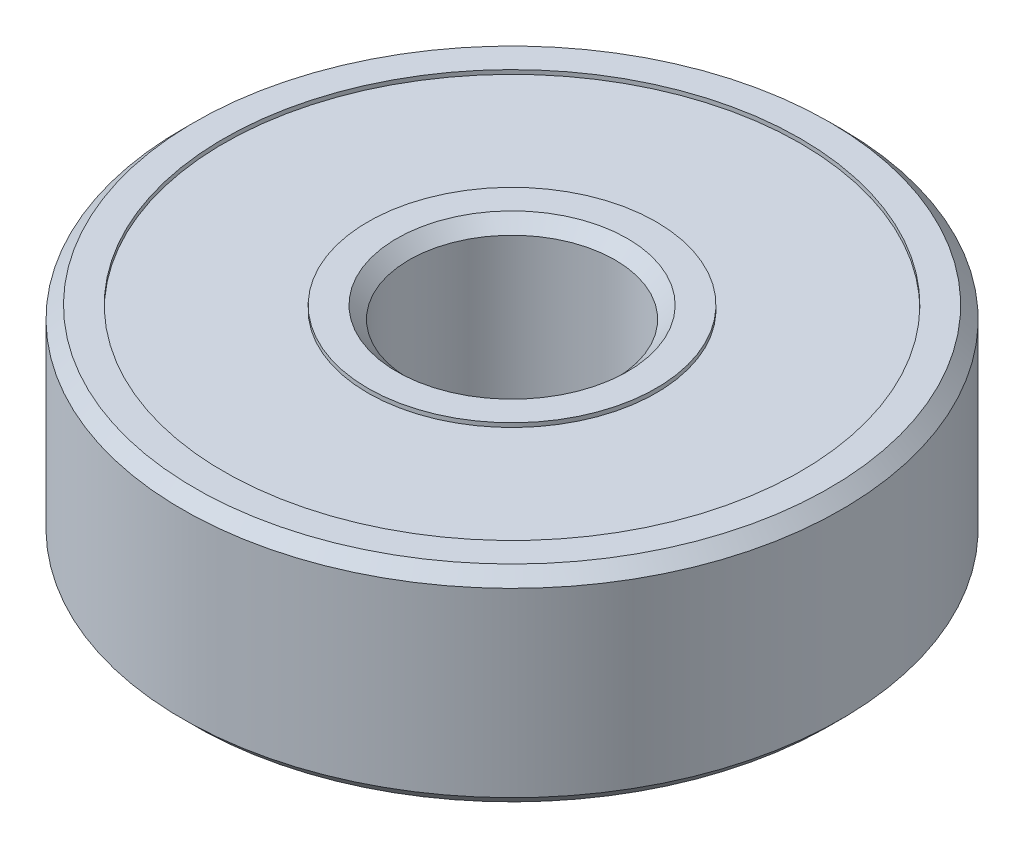
from build123d import *


with BuildPart() as part:
    # Sketch1 → Revolution1 (revolve)
    with BuildSketch(Plane.XY):
        Polygon((2.5, -2.2), (2.5, 2.2), (2.8, 2.5), (3.5, 2.5), (3.5, 2.4), (7, 2.4), (7, 2.5), (7.7, 2.5), (8, 2.2), (8, -2.2), (7.7, -2.5), (7, -2.5), (7, -2.4), (3.5, -2.4), (3.5, -2.5), (2.8, -2.5), align=None)
    revolve(axis=Axis((0, 0, 0), (0, 1, 0)))


solid = part.part
